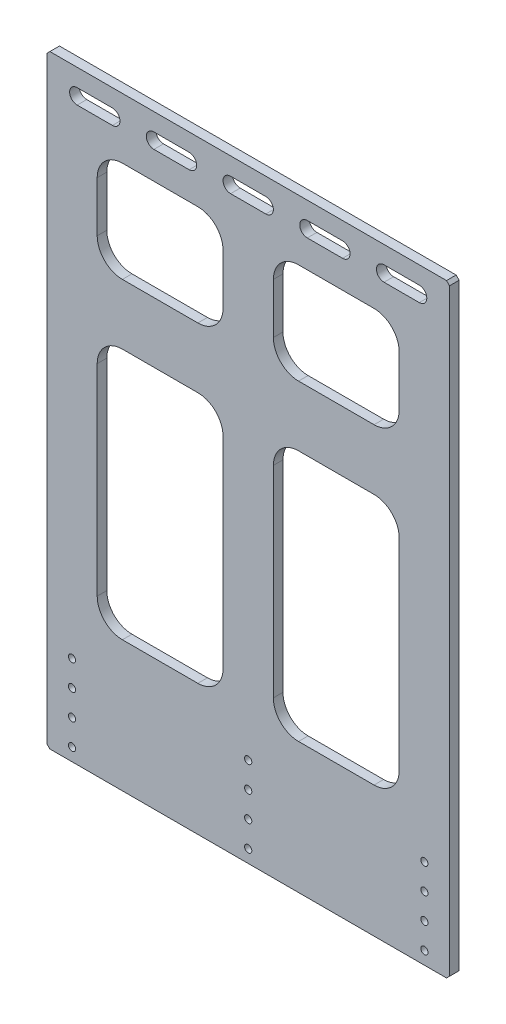
from build123d import *

# Parameters (mm, degrees)
SKETCH1_W               = 400
SKETCH1_H               = 600
BOSS_EXTRUDE1_DEPTH     = 9.525
F_1_4_CLEARANCE_HOLE1_D = 7.14248
LPATTERN1_COUNT         = 2
LPATTERN1_PITCH         = 50.8
CUT_EXTRUDE2_DEPTH      = 10.525
LPATTERN2_COUNT         = 3
LPATTERN2_PITCH         = 76.2
LPATTERN2_COL_COUNT     = 3
LPATTERN2_COL_PITCH     = 76.2
SKETCH6_W               = 300
SKETCH6_H               = 250
SKETCH6_H_2             = 100
CUT_EXTRUDE1_DEPTH      = 10.525
SKETCH7_W               = 50
SKETCH7_H               = 410
BOSS_EXTRUDE2_DEPTH     = 9.525
FILLET1_R               = 25
CHAMFER2_SIZE           = 3


with BuildPart() as part:
    # Sketch1 → Boss-Extrude1 (new body)
    with BuildSketch(Plane.XY):
        with Locations((0, 300)):
            Rectangle(SKETCH1_W, SKETCH1_H)
    extrude(amount=BOSS_EXTRUDE1_DEPTH)

    # 1/4 Clearance Hole1 (through all)
    with Locations(Plane.XY.offset(9.525)):
        with Locations((-175, 12.7), (-175, 38.1), (175, 38.1), (175, 12.7), (0, 38.1), (0, 12.7)):
            f_1_4_clearance_hole1 = Hole(F_1_4_CLEARANCE_HOLE1_D / 2)

    # LPattern1: 1/4 Clearance Hole1 ×2
    with Locations(*[(0, i * LPATTERN1_PITCH, 0) for i in range(1, LPATTERN1_COUNT)]):
        add(f_1_4_clearance_hole1, mode=Mode.SUBTRACT)

    # Sketch8 → Cut-Extrude2 (cut, through all)
    with BuildSketch(Plane.XY.offset(9.525)):
        with BuildLine():
            Line((-17.5, 582.5), (17.5, 582.5))
            ThreePointArc((17.5, 582.5), (25, 575), (17.5, 567.5))
            Line((17.5, 567.5), (-17.5, 567.5))
            ThreePointArc((-17.5, 567.5), (-25, 575), (-17.5, 582.5))
        make_face()
    cut_extrude2 = extrude(amount=-CUT_EXTRUDE2_DEPTH, mode=Mode.SUBTRACT)

    # LPattern2: Cut-Extrude2 ×3
    with Locations(*[(i * LPATTERN2_PITCH, 0, 0) for i in range(1, LPATTERN2_COUNT)]):
        add(cut_extrude2, mode=Mode.SUBTRACT)

    # LPattern2 col: Cut-Extrude2 ×3
    with Locations(*[(-i * LPATTERN2_COL_PITCH, 0, 0) for i in range(1, LPATTERN2_COL_COUNT)]):
        add(cut_extrude2, mode=Mode.SUBTRACT)

    # Sketch6 → Cut-Extrude1 (cut, through all)
    with BuildSketch(Plane.XY.offset(9.525)):
        with Locations((0, 255)):
            Rectangle(SKETCH6_W, SKETCH6_H)
        with Locations((0, 490)):
            Rectangle(SKETCH6_W, SKETCH6_H_2)
    extrude(amount=-CUT_EXTRUDE1_DEPTH, mode=Mode.SUBTRACT)

    # Sketch7 → Boss-Extrude2 (add, through all)
    with BuildSketch(Plane.XY.offset(9.525)):
        with Locations((0, 335)):
            Rectangle(SKETCH7_W, SKETCH7_H)
    extrude(amount=-BOSS_EXTRUDE2_DEPTH)

    # Fillet1
    fillet1_edges = [part.edges().sort_by_distance(p)[0] for p in [
        (-150, 130, 4.7625),
        (-150, 380, 4.7625),
        (150, 380, 4.7625),
        (150, 130, 4.7625),
        (-150, 440, 4.7625),
        (-150, 540, 4.7625),
        (150, 540, 4.7625),
        (150, 440, 4.7625),
        (-25, 440, 4.7625),
        (25, 440, 4.7625),
        (25, 540, 4.7625),
        (-25, 130, 4.7625),
        (-25, 540, 4.7625),
        (25, 380, 4.7625),
        (25, 130, 4.7625),
        (-25, 380, 4.7625),
    ]]
    fillet(fillet1_edges, radius=FILLET1_R)

    # Chamfer2
    chamfer2_edges = [part.edges().sort_by_distance(p)[0] for p in [
        (-200, 600, 4.7625),
        (200, 600, 4.7625),
        (200, 0, 4.7625),
        (-200, 0, 4.7625),
    ]]
    chamfer(chamfer2_edges, length=CHAMFER2_SIZE)


solid = part.part
